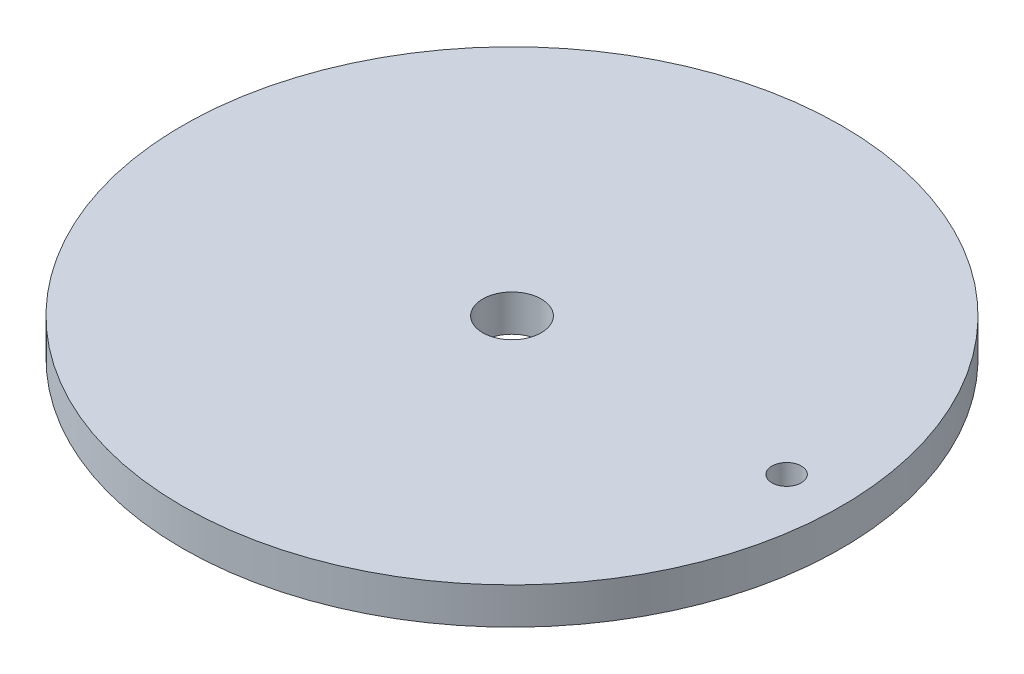
from build123d import *

# Parameters (mm, degrees)
SKETCH1_R           = 45
SKETCH1_R_2         = 4
SKETCH1_R_3         = 2
BOSS_EXTRUDE1_DEPTH = 5


with BuildPart() as part:
    # Sketch1 → Boss-Extrude1 (new body)
    with BuildSketch(Plane(origin=(0, 0, 0), x_dir=(1, 0, 0), z_dir=(0, 1, 0))):
        Circle(SKETCH1_R)
        Circle(SKETCH1_R_2, mode=Mode.SUBTRACT)
        with Locations((37.5, 0)):
            Circle(SKETCH1_R_3, mode=Mode.SUBTRACT)
    extrude(amount=BOSS_EXTRUDE1_DEPTH)


solid = part.part
